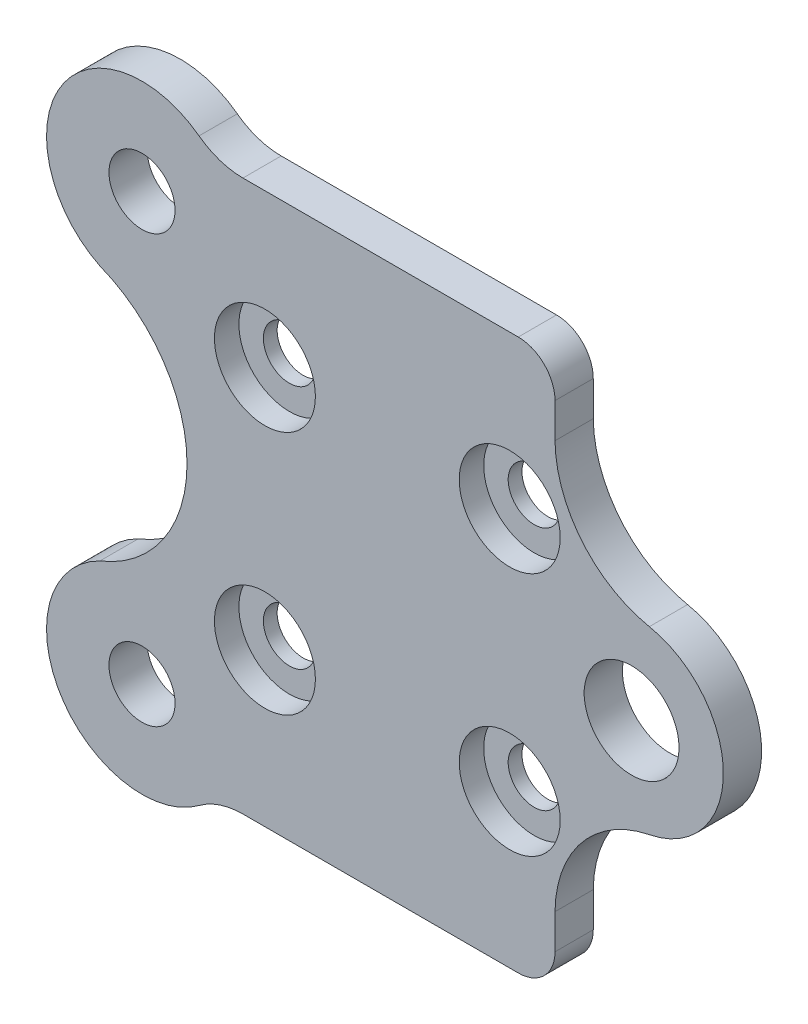
from build123d import *

# Parameters (mm, degrees)
MODEL_R             = 2.7
MODEL_R_2           = 3.875
MODEL_R_3           = 2.125
BOSS_EXTRUDE1_DEPTH = 3.125
MODEL_3_R           = 4.125
MODEL_3_R_2         = 2.125
CUT_EXTRUDE1_DEPTH  = 2
FILLET1_R           = 3
FILLET2_R           = 6


with BuildPart() as part:
    # Model → Boss-Extrude1 (new body)
    with BuildSketch(Plane.XY):
        with BuildLine():
            Line((85.751165458, 39.930508181), (57.940219492, 39.930508181))
            ThreePointArc((57.940219492, 39.930508181), (45.846452894, 39.648352972), (48.573590158, 27.862703884))
            ThreePointArc((48.573590158, 27.862703884), (55.686625956, 17.430508181), (48.573590158, 6.998312478))
            ThreePointArc((48.573590158, 6.998312478), (45.846452894, -4.78733661), (57.940219492, -5.069491819))
            Line((57.940219492, -5.069491819), (85.751165458, -5.069491819))
            Line((85.751165458, -5.069491819), (85.751165458, 0.769903947))
            ThreePointArc((85.751165458, 0.769903947), (87.9590359, 6.783913161), (93.457436342, 10.071859524))
            ThreePointArc((93.457436342, 10.071859524), (99.50819863, 17.430508181), (93.457436342, 24.789156838))
            ThreePointArc((93.457436342, 24.789156838), (87.9590359, 28.077103201), (85.751165458, 34.091112415))
            Line((85.751165458, 34.091112415), (85.751165458, 39.930508181))
        make_face()
        with Locations((52.008207521, -0.004787091)):
            Circle(MODEL_R, mode=Mode.SUBTRACT)
        with Locations((52.008207521, 34.865803453)):
            Circle(MODEL_R, mode=Mode.SUBTRACT)
        with Locations((92.00819863, 17.430508181)):
            Circle(MODEL_R_2, mode=Mode.SUBTRACT)
        with Locations((62.05010788, 7.430508181)):
            Circle(MODEL_R_3, mode=Mode.SUBTRACT)
        with Locations((82.050054867, 7.430508181)):
            Circle(MODEL_R_3, mode=Mode.SUBTRACT)
        with Locations((62.05010788, 27.430508181)):
            Circle(MODEL_R_3, mode=Mode.SUBTRACT)
        with Locations((82.050054867, 27.430508181)):
            Circle(MODEL_R_3, mode=Mode.SUBTRACT)
    extrude(amount=-BOSS_EXTRUDE1_DEPTH)

    # Model_3 → Cut-Extrude1 (cut)
    # profile 1 of 4: a face of its own
    with BuildSketch(Plane.XY):
        with Locations((82.050054867, 27.430508181)):
            Circle(MODEL_3_R)
    # profile 2 of 4: a face of its own
    with BuildSketch(Plane.XY):
        with Locations((62.05010788, 27.430508181)):
            Circle(MODEL_3_R)
        with Locations((62.05010788, 27.430508181)):
            Circle(MODEL_3_R_2, mode=Mode.SUBTRACT)
    # profile 3 of 4: a face of its own
    with BuildSketch(Plane.XY):
        with Locations((62.05010788, 7.430508181)):
            Circle(MODEL_3_R)
        with Locations((62.05010788, 7.430508181)):
            Circle(MODEL_3_R_2, mode=Mode.SUBTRACT)
    # profile 4 of 4: a face of its own
    with BuildSketch(Plane.XY):
        with Locations((82.050054867, 7.430508181)):
            Circle(MODEL_3_R)
        with Locations((82.050054867, 7.430508181)):
            Circle(MODEL_3_R_2, mode=Mode.SUBTRACT)
    extrude(amount=-CUT_EXTRUDE1_DEPTH, mode=Mode.SUBTRACT)

    # Fillet1
    fillet1_edges = [part.edges().sort_by_distance(p)[0] for p in [
        (85.751165458, -5.069491819, -1.5625),
        (85.751165458, 39.930508181, -1.5625),
    ]]
    fillet(fillet1_edges, radius=FILLET1_R)

    # Fillet2
    fillet2_edges = [part.edges().sort_by_distance(p)[0] for p in [
        (57.940219492, 39.930508181, -1.5625),
        (57.940219492, -5.069491819, -1.5625),
    ]]
    fillet(fillet2_edges, radius=FILLET2_R)


solid = part.part
